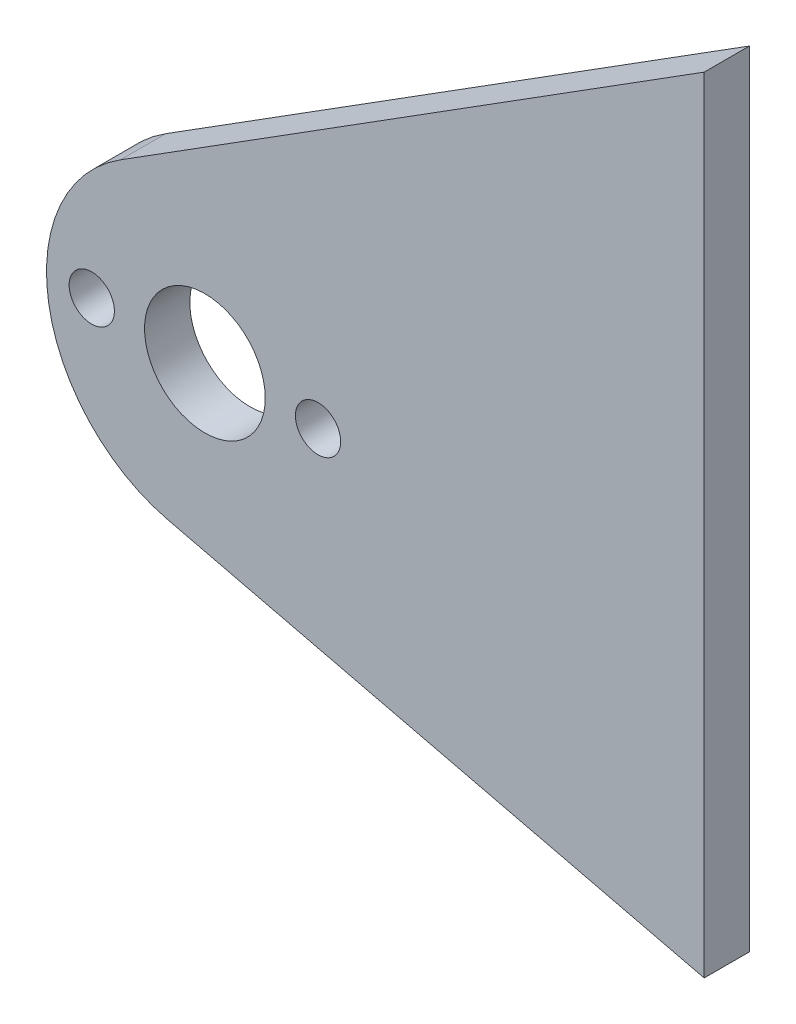
from build123d import *

# Parameters (mm, degrees)
MODEL_R                 = 1.5
MODEL_R_2               = 4.000000302
SALIENTE_EXTRUIR1_DEPTH = 3


with BuildPart() as part:
    # Model → Saliente-Extruir1 (new body)
    with BuildSketch(Plane.XY):
        with BuildLine():
            Line((33.092598, 34.66167), (33.092598, -17.33833))
            Line((33.092598, -17.33833), (-2.449857, -8.810201))
            ThreePointArc((-2.449857, -8.810201), (-10.360174953, -0.307858771), (-5.597443, 10.283616))
            Line((-5.597443, 10.283616), (33.092598, 34.66167))
        make_face()
        with Locations((7.5, 1.4)):
            Circle(MODEL_R, mode=Mode.SUBTRACT)
        with Locations((-7.5, 1.4)):
            Circle(MODEL_R, mode=Mode.SUBTRACT)
        with Locations((-3.02e-07, 1.399999887)):
            Circle(MODEL_R_2, mode=Mode.SUBTRACT)
    extrude(amount=SALIENTE_EXTRUIR1_DEPTH)


solid = part.part
